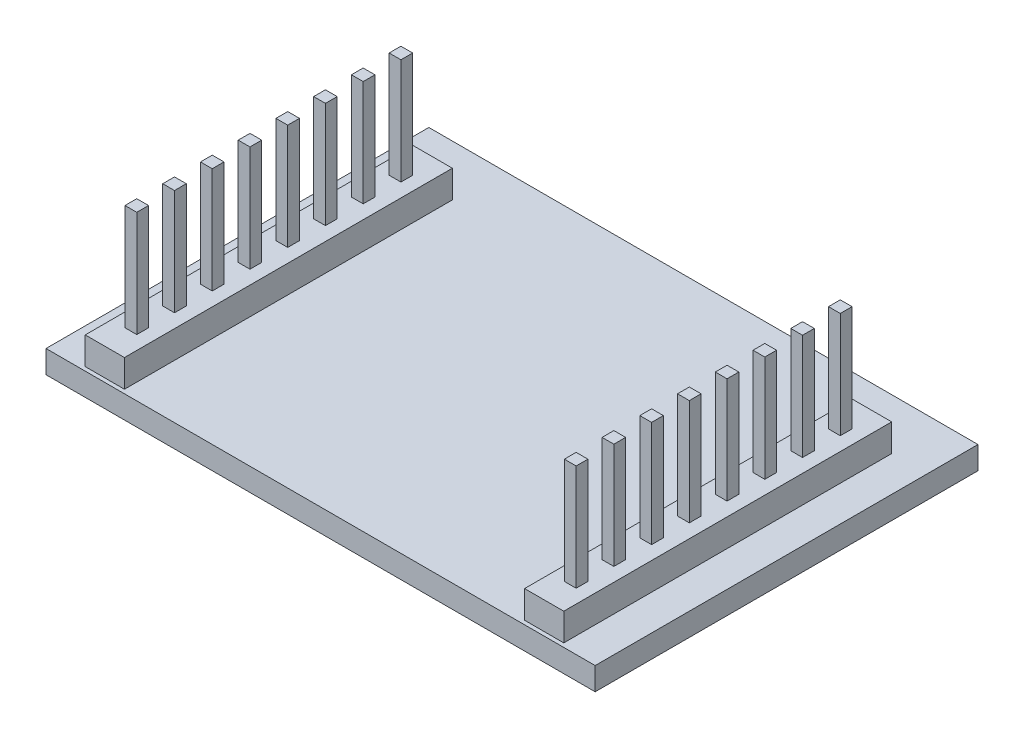
from build123d import *

# Parameters (mm, degrees)
SKETCH1_W           = 35
SKETCH1_H           = 24.4
BOSS_EXTRUDE1_DEPTH = 1.45
SKETCH2_W           = 2.5
SKETCH2_H           = 20.9
SKETCH2_W_2         = 2.498206115
BOSS_EXTRUDE2_DEPTH = 1.75
SKETCH3_W           = 0.75
SKETCH3_H           = 0.75
BOSS_EXTRUDE3_DEPTH = 6.75
SKETCH5_W           = 0.75
SKETCH5_H           = 0.75
BOSS_EXTRUDE4_DEPTH = 6.75
BOSS_EXTRUDE5_DEPTH = 1


with BuildPart() as part:
    # Sketch1 → Boss-Extrude1 (new body)
    with BuildSketch(Plane(origin=(0, 0, 0), x_dir=(1, 0, 0), z_dir=(0, 1, 0))):
        Rectangle(SKETCH1_W, SKETCH1_H)
    extrude(amount=BOSS_EXTRUDE1_DEPTH)

    # Sketch2 → Boss-Extrude2 (add)
    with BuildSketch(Plane(origin=(0, 1.45, 0), x_dir=(1, 0, 0), z_dir=(0, 1, 0))):
        with Locations((-14, -1.5)):
            Rectangle(SKETCH2_W, SKETCH2_H)
        with Locations((14.000896943, -1.5)):
            Rectangle(SKETCH2_W_2, SKETCH2_H)
    extrude(amount=BOSS_EXTRUDE2_DEPTH)

    # Sketch3 → Boss-Extrude3 (add)
    with BuildSketch(Plane(origin=(0, 3.2, 0), x_dir=(1, 0, 0), z_dir=(0, 1, 0))):
        with Locations((-14, 6.92)):
            Rectangle(SKETCH3_W, SKETCH3_H)
        with Locations((-14, 4.515)):
            Rectangle(SKETCH3_W, SKETCH3_H)
        with Locations((-14, 2.11)):
            Rectangle(SKETCH3_W, SKETCH3_H)
        with Locations((-14, -0.295)):
            Rectangle(SKETCH3_W, SKETCH3_H)
        with Locations((-14, -2.7)):
            Rectangle(SKETCH3_W, SKETCH3_H)
        with Locations((-14, -5.105)):
            Rectangle(SKETCH3_W, SKETCH3_H)
        with Locations((-14, -7.51)):
            Rectangle(SKETCH3_W, SKETCH3_H)
        with Locations((-14, -9.915)):
            Rectangle(SKETCH3_W, SKETCH3_H)
    extrude(amount=BOSS_EXTRUDE3_DEPTH)

    # Sketch5 → Boss-Extrude4 (add)
    with BuildSketch(Plane(origin=(0, 3.2, 0), x_dir=(1, 0, 0), z_dir=(0, 1, 0))):
        with Locations((14.001793885, 6.92)):
            Rectangle(SKETCH5_W, SKETCH5_H)
        with Locations((14.001793885, 4.515)):
            Rectangle(SKETCH5_W, SKETCH5_H)
        with Locations((14.001793885, 2.11)):
            Rectangle(SKETCH5_W, SKETCH5_H)
        with Locations((14.001793885, -0.295)):
            Rectangle(SKETCH5_W, SKETCH5_H)
        with Locations((14.001793885, -2.7)):
            Rectangle(SKETCH5_W, SKETCH5_H)
        with Locations((14.001793885, -5.105)):
            Rectangle(SKETCH5_W, SKETCH5_H)
        with Locations((14.001793885, -7.51)):
            Rectangle(SKETCH5_W, SKETCH5_H)
        with Locations((14.001793885, -9.915)):
            Rectangle(SKETCH5_W, SKETCH5_H)
    extrude(amount=BOSS_EXTRUDE4_DEPTH)

    # Sketch6 → Boss-Extrude5 (add)
    with BuildSketch(Plane(origin=(0, 0, 0), x_dir=(-1, 0, 0), z_dir=(0, -1, 0))):
        with BuildLine():
            Line((-10.862530521, 1.602014843), (-11.137370265, 1.391678305))
            add(Edge.make_bspline(
                [(-11.137370265, 1.391678305), (-11.156976153, 1.415044275), (-11.1959236, 1.46146119), (-11.258582803, 1.526640735), (-11.323884446, 1.587705996), (-11.391803567, 1.644947876), (-11.463562686, 1.696364642), (-11.537423485, 1.744635745), (-11.61462153, 1.787903483), (-11.721373265, 1.840366469), (-11.861021113, 1.895112624), (-12.036815952, 1.941015855), (-12.220327051, 1.970237031), (-12.34552465, 1.973401872), (-12.409205201, 1.975011638)],
                knots=[0, 0, 0, 0, 9.1485e-05, 0.000181737, 0.000271024, 0.000359627, 0.000447979, 0.000535687, 0.000624217, 0.000713268, 0.000892422, 0.00107303, 0.001257466, 0.001448389, 0.001448389, 0.001448389, 0.001448389], degree=3))
            add(Edge.make_bspline(
                [(-12.409205201, 1.975011638), (-12.4442885, 1.974607676), (-12.514129493, 1.9738035), (-12.617777966, 1.963194375), (-12.719491017, 1.948283165), (-12.819202484, 1.926157841), (-12.916785442, 1.898185222), (-13.012877844, 1.864759808), (-13.106088444, 1.823404969), (-13.197706682, 1.777696709), (-13.285485893, 1.726069264), (-13.368540941, 1.669755912), (-13.446568909, 1.609386816), (-13.519631521, 1.544735709), (-13.587803469, 1.476093749), (-13.65059078, 1.402729407), (-13.70777619, 1.324877234), (-13.760493216, 1.243563826), (-13.807705949, 1.159026034), (-13.847235828, 1.070950964), (-13.882240951, 0.980846861), (-13.909940193, 0.8876957), (-13.93186471, 0.792152934), (-13.946992373, 0.693962146), (-13.957480844, 0.593328467), (-13.958281021, 0.525119154), (-13.958684368, 0.490736799)],
                knots=[0, 0, 0, 0, 0.000105206, 0.000209435, 0.000312261, 0.00041348, 0.000515565, 0.000616682, 0.000718413, 0.000821258, 0.000923708, 0.001023662, 0.001122111, 0.001219464, 0.00131614, 0.001412112, 0.001508869, 0.001605718, 0.001702691, 0.001799013, 0.001895107, 0.001992482, 0.002090281, 0.00218895, 0.002290387, 0.00239349, 0.00239349, 0.00239349, 0.00239349], degree=3))
            add(Edge.make_bspline(
                [(-13.958684368, 0.490736799), (-13.957422549, 0.439005479), (-13.954945134, 0.337437894), (-13.9328968, 0.188667283), (-13.899391709, 0.046146609), (-13.849176132, -0.089233233), (-13.787257081, -0.219141591), (-13.70901647, -0.341380444), (-13.618399933, -0.457797009), (-13.514125513, -0.565639957), (-13.399719697, -0.664153682), (-13.276971785, -0.750904263), (-13.146187498, -0.823219146), (-13.008810867, -0.883395092), (-12.863784754, -0.92965182), (-12.711369951, -0.962215944), (-12.551897956, -0.983458124), (-12.442928556, -0.985491812), (-12.387470425, -0.986526823)],
                knots=[0, 0, 0, 0, 0.000155106, 0.000304531, 0.000450265, 0.000593548, 0.000736853, 0.000881182, 0.001028026, 0.001178769, 0.001330408, 0.001480379, 0.001628835, 0.001777978, 0.001929641, 0.002084627, 0.002245075, 0.00241136, 0.00241136, 0.00241136, 0.00241136], degree=3))
            add(Edge.make_bspline(
                [(-12.387470425, -0.986526823), (-12.326367736, -0.984838044), (-12.206103027, -0.981514121), (-12.029735001, -0.953354872), (-11.860899235, -0.907696954), (-11.699586649, -0.843799032), (-11.546252003, -0.760733744), (-11.400655342, -0.660035866), (-11.262673772, -0.540747534), (-11.17970249, -0.449664405), (-11.137370265, -0.40319349)],
                knots=[0, 0, 0, 0, 0.00018322, 0.00036062, 0.000534275, 0.000707044, 0.000879893, 0.001056289, 0.001237208, 0.001425665, 0.001425665, 0.001425665, 0.001425665], degree=3))
            Line((-11.137370265, -0.40319349), (-10.862530521, -0.611426663))
            add(Edge.make_bspline(
                [(-10.862530521, -0.611426663), (-10.884648631, -0.639965115), (-10.928778907, -0.696905321), (-11.000236924, -0.777177031), (-11.075514221, -0.852681066), (-11.155169931, -0.922808688), (-11.238287723, -0.988963153), (-11.326360035, -1.049264985), (-11.418229067, -1.104555869), (-11.513583546, -1.155182793), (-11.612322159, -1.20010004), (-11.714326594, -1.238553808), (-11.81915717, -1.271678698), (-11.926818678, -1.298930634), (-12.037534435, -1.320201718), (-12.150904909, -1.334421393), (-12.267174784, -1.344163308), (-12.345616205, -1.345051223), (-12.38536706, -1.345501182)],
                knots=[0, 0, 0, 0, 0.000108293, 0.000216068, 0.000322162, 0.000427957, 0.000534281, 0.00064066, 0.000747915, 0.000855806, 0.000964371, 0.001073102, 0.001182643, 0.001294024, 0.001406092, 0.001520624, 0.001636667, 0.001755891, 0.001755891, 0.001755891, 0.001755891], degree=3))
            add(Edge.make_bspline(
                [(-12.38536706, -1.345501182), (-12.423010727, -1.34523919), (-12.497446417, -1.344721132), (-12.607345169, -1.336328964), (-12.714334749, -1.324879228), (-12.818109375, -1.307639096), (-12.91923535, -1.287294756), (-13.016795935, -1.2600235), (-13.111751145, -1.229474333), (-13.203719486, -1.193569346), (-13.292779186, -1.153053164), (-13.378642997, -1.107261605), (-13.461271429, -1.05657974), (-13.54147685, -1.00212473), (-13.618074434, -0.942147428), (-13.691727959, -0.877480794), (-13.762850436, -0.808342783), (-13.806853121, -0.758487929), (-13.828976835, -0.733421855)],
                knots=[0, 0, 0, 0, 0.0001129, 0.000223246, 0.000330481, 0.000435603, 0.000538732, 0.000639764, 0.000739316, 0.000837878, 0.000935767, 0.001032686, 0.001129604, 0.00122645, 0.001323362, 0.001421241, 0.001520399, 0.001620667, 0.001620667, 0.001620667, 0.001620667], degree=3))
            add(Edge.make_bspline(
                [(-13.828976835, -0.733421855), (-13.864412479, -0.689880666), (-13.934855956, -0.603323956), (-14.024981639, -0.463037975), (-14.102129195, -0.316569766), (-14.164505115, -0.163149837), (-14.213267849, -0.00312245), (-14.247049044, 0.163593065), (-14.269000648, 0.336841007), (-14.271510937, 0.454677795), (-14.272786932, 0.51457494)],
                knots=[0, 0, 0, 0, 0.000168306, 0.00033458, 0.000499224, 0.000664315, 0.00083066, 0.00100034, 0.001174094, 0.001353718, 0.001353718, 0.001353718, 0.001353718], degree=3))
            add(Edge.make_bspline(
                [(-14.272786932, 0.51457494), (-14.271231738, 0.577530393), (-14.268171992, 0.701391318), (-14.242176196, 0.883165271), (-14.2003574, 1.05731667), (-14.140960512, 1.223520414), (-14.06565516, 1.382650695), (-13.972628546, 1.533491899), (-13.862961404, 1.677008699), (-13.737513837, 1.81102345), (-13.599946501, 1.933562803), (-13.452627687, 2.041369007), (-13.29584574, 2.131086523), (-13.131327889, 2.206082685), (-12.957842207, 2.263727148), (-12.775758838, 2.304080335), (-12.585419923, 2.329197451), (-12.455557498, 2.332372659), (-12.389573791, 2.333985997)],
                knots=[0, 0, 0, 0, 0.000188789, 0.000371431, 0.000549644, 0.000725278, 0.00089996, 0.001076844, 0.001255917, 0.001440951, 0.001626689, 0.001807878, 0.001987546, 0.002167657, 0.002349462, 0.002534866, 0.002726448, 0.002924344, 0.002924344, 0.002924344, 0.002924344], degree=3))
            add(Edge.make_bspline(
                [(-12.389573791, 2.333985997), (-12.349359319, 2.333503859), (-12.269758821, 2.332549515), (-12.152006169, 2.323243373), (-12.037363842, 2.307729767), (-11.92575286, 2.286613697), (-11.816630244, 2.260406375), (-11.710830003, 2.226266077), (-11.607731316, 2.187229546), (-11.507984408, 2.14227108), (-11.412067858, 2.091804338), (-11.320011539, 2.036388715), (-11.232546681, 1.976092909), (-11.149057832, 1.911429734), (-11.070941621, 1.841031175), (-10.995980142, 1.766833579), (-10.926719064, 1.686699755), (-10.883965869, 1.630294821), (-10.862530521, 1.602014843)],
                knots=[0, 0, 0, 0, 0.000120626, 0.000238766, 0.000354085, 0.000467531, 0.000579423, 0.000690512, 0.000800803, 0.000910007, 0.001018518, 0.001125773, 0.001232152, 0.001337058, 0.001442329, 0.001547432, 0.001653292, 0.001759736, 0.001759736, 0.001759736, 0.001759736], degree=3))
        make_face()
        with BuildLine():
            Line((-10.279197188, 1.301934715), (-9.965094624, 1.301934715))
            Line((-9.965094624, 1.301934715), (-9.965094624, 0.115636638))
            add(Edge.make_bspline(
                [(-9.965094624, 0.115636638), (-9.964952719, 0.080813889), (-9.964681262, 0.014199601), (-9.962840321, -0.081655586), (-9.958510227, -0.169072298), (-9.953096403, -0.248101035), (-9.946134266, -0.318728427), (-9.937850906, -0.380707784), (-9.928592484, -0.434741968), (-9.91952977, -0.467285324), (-9.915314977, -0.482420253)],
                knots=[0, 0, 0, 0, 0.00010447, 0.000199845, 0.000287586, 0.000367011, 0.000437473, 0.000500438, 0.00055462, 0.000601725, 0.000601725, 0.000601725, 0.000601725], degree=3))
            add(Edge.make_bspline(
                [(-9.915314977, -0.482420253), (-9.908553522, -0.501443124), (-9.89517118, -0.539093385), (-9.870897697, -0.59348239), (-9.84086936, -0.643857672), (-9.808009532, -0.692161745), (-9.770110125, -0.736963732), (-9.727650654, -0.778187976), (-9.682052417, -0.817392067), (-9.614297393, -0.863776859), (-9.521638127, -0.913492189), (-9.399985372, -0.956388007), (-9.268081146, -0.982023827), (-9.176916427, -0.984998082), (-9.130058566, -0.986526823)],
                knots=[0, 0, 0, 0, 6.0561e-05, 0.000119863, 0.000178304, 0.000236261, 0.000294971, 0.000353969, 0.000413668, 0.000475127, 0.000599968, 0.00072792, 0.000860749, 0.001001226, 0.001001226, 0.001001226, 0.001001226], degree=3))
            add(Edge.make_bspline(
                [(-9.130058566, -0.986526823), (-9.083205059, -0.984965575), (-8.99255219, -0.981944848), (-8.862097221, -0.957161309), (-8.742845807, -0.91575562), (-8.635994855, -0.857948208), (-8.542029015, -0.787206145), (-8.463724596, -0.704197337), (-8.399117342, -0.61154795), (-8.370907921, -0.542423671), (-8.356721227, -0.507660637)],
                knots=[0, 0, 0, 0, 0.000140477, 0.000271796, 0.000396637, 0.000517726, 0.000634816, 0.00074789, 0.000858929, 0.000971266, 0.000971266, 0.000971266, 0.000971266], degree=3))
            add(Edge.make_bspline(
                [(-8.356721227, -0.507660637), (-8.352526996, -0.493694339), (-8.343254578, -0.462818263), (-8.333292227, -0.410438515), (-8.324317765, -0.34797391), (-8.316654589, -0.275015702), (-8.311189426, -0.191754549), (-8.3082434, -0.098216473), (-8.304915124, 0.005304887), (-8.304864608, 0.077772646), (-8.304838214, 0.115636638)],
                knots=[0, 0, 0, 0, 4.3723e-05, 9.6661e-05, 0.000159723, 0.000233047, 0.000316669, 0.000409984, 0.000513788, 0.000627372, 0.000627372, 0.000627372, 0.000627372], degree=3))
            Line((-8.304838214, 0.115636638), (-8.304838214, 1.301934715))
            Line((-8.304838214, 1.301934715), (-7.99073565, 1.301934715))
            Line((-7.99073565, 1.301934715), (-7.99073565, 0.056742407))
            add(Edge.make_bspline(
                [(-7.99073565, 0.056742407), (-7.991177344, 0.014435236), (-7.992034293, -0.067646464), (-7.997541636, -0.186930575), (-8.006991249, -0.29809282), (-8.021333934, -0.40119204), (-8.038199609, -0.496149522), (-8.059955881, -0.583086968), (-8.085934119, -0.661736522), (-8.115239634, -0.733478299), (-8.149861502, -0.798525193), (-8.186688522, -0.860261009), (-8.229213294, -0.917153945), (-8.273983528, -0.972036082), (-8.323785184, -1.022177609), (-8.377685043, -1.068729085), (-8.434924463, -1.112402117), (-8.496773661, -1.151493396), (-8.562329724, -1.186710042), (-8.631673581, -1.21792612), (-8.705654579, -1.242628697), (-8.783318216, -1.263939363), (-8.865044995, -1.280653832), (-8.950756129, -1.292440398), (-9.040422745, -1.299665729), (-9.101532204, -1.300302774), (-9.132863053, -1.300629387)],
                knots=[0, 0, 0, 0, 0.00012692, 0.000246243, 0.000358153, 0.000461473, 0.000558423, 0.000647357, 0.000730057, 0.000806749, 0.000879504, 0.000950929, 0.001022168, 0.001092368, 0.001163264, 0.001233837, 0.001305913, 0.001379045, 0.001453076, 0.001529034, 0.001606858, 0.001686798, 0.001770538, 0.001856901, 0.001946219, 0.002040193, 0.002040193, 0.002040193, 0.002040193], degree=3))
            add(Edge.make_bspline(
                [(-9.132863053, -1.300629387), (-9.163959568, -1.30028968), (-9.225067113, -1.299622124), (-9.314738357, -1.292480316), (-9.400686963, -1.280672146), (-9.482607362, -1.263816928), (-9.560581759, -1.242777858), (-9.634925999, -1.217774323), (-9.704769562, -1.186693841), (-9.770951566, -1.151716284), (-9.832953954, -1.112151008), (-9.891062532, -1.068782969), (-9.945199385, -1.021676906), (-9.995376453, -0.971029548), (-10.040889429, -0.916212612), (-10.082305471, -0.857667052), (-10.120262176, -0.795972963), (-10.154614967, -0.729909801), (-10.184126722, -0.657337791), (-10.210181968, -0.577040694), (-10.231492606, -0.488138177), (-10.248835075, -0.390706249), (-10.262786515, -0.285211207), (-10.272472658, -0.171042792), (-10.277888488, -0.0484791), (-10.27875155, 0.03617079), (-10.279197188, 0.079879427)],
                knots=[0, 0, 0, 0, 9.3273e-05, 0.00018329, 0.000269653, 0.000353393, 0.000434009, 0.000511834, 0.000588433, 0.000663082, 0.000736214, 0.00080885, 0.000880413, 0.000951309, 0.001022496, 0.001093894, 0.001166283, 0.00123966, 0.001317, 0.001401032, 0.001492689, 0.001591018, 0.001697812, 0.001811817, 0.001934642, 0.002065769, 0.002065769, 0.002065769, 0.002065769], degree=3))
            Line((-10.279197188, 0.079879427), (-10.279197188, 1.301934715))
        make_face()
        with BuildLine():
            Line((-6.06124847, 0.982924299), (-6.274389496, 0.763473177))
            add(Edge.make_bspline(
                [(-6.274389496, 0.763473177), (-6.292779999, 0.784786323), (-6.328234725, 0.82587556), (-6.384466206, 0.880812627), (-6.44048981, 0.926949566), (-6.495538623, 0.965901824), (-6.550996892, 0.995350971), (-6.60621381, 1.016845833), (-6.661246549, 1.030147639), (-6.698032584, 1.031862077), (-6.716096227, 1.032703946)],
                knots=[0, 0, 0, 0, 8.4426e-05, 0.000162764, 0.000235478, 0.000301992, 0.000364722, 0.000423315, 0.00047944, 0.00053359, 0.00053359, 0.00053359, 0.00053359], degree=3))
            add(Edge.make_bspline(
                [(-6.716096227, 1.032703946), (-6.738235616, 1.031629073), (-6.781802802, 1.029513875), (-6.844228621, 1.008400445), (-6.902179246, 0.975991706), (-6.952336226, 0.930023123), (-6.994823906, 0.877258854), (-7.025837587, 0.818262529), (-7.04480357, 0.754814485), (-7.047208302, 0.710784628), (-7.048427957, 0.688453145)],
                knots=[0, 0, 0, 0, 6.6207e-05, 0.000130286, 0.000195595, 0.000264126, 0.000333001, 0.000397918, 0.000462926, 0.000529831, 0.000529831, 0.000529831, 0.000529831], degree=3))
            add(Edge.make_bspline(
                [(-7.048427957, 0.688453145), (-7.047317145, 0.668241101), (-7.045098652, 0.62787399), (-7.027851973, 0.568325956), (-7.0003859, 0.510268918), (-6.974715706, 0.474706011), (-6.961488855, 0.456381831)],
                knots=[0, 0, 0, 0, 6.0557e-05, 0.000120943, 0.000184606, 0.000252278, 0.000252278, 0.000252278, 0.000252278], degree=3))
            add(Edge.make_bspline(
                [(-6.961488855, 0.456381831), (-6.953525361, 0.446597246), (-6.936576068, 0.425771992), (-6.904767553, 0.396868138), (-6.86874505, 0.364925887), (-6.825425113, 0.33298905), (-6.776674085, 0.299357325), (-6.7214348, 0.265355192), (-6.661460296, 0.228390767), (-6.618522989, 0.204946332), (-6.5962044, 0.192760036)],
                knots=[0, 0, 0, 0, 3.7796e-05, 8.0443e-05, 0.000128658, 0.000182224, 0.000241732, 0.000306315, 0.000376777, 0.000453048, 0.000453048, 0.000453048, 0.000453048], degree=3))
            add(Edge.make_bspline(
                [(-6.5962044, 0.192760036), (-6.568990822, 0.177515133), (-6.516423152, 0.148067), (-6.441730385, 0.102357297), (-6.373943344, 0.056925873), (-6.312487677, 0.012258599), (-6.258545868, -0.032894269), (-6.210481315, -0.076802026), (-6.169492871, -0.120791334), (-6.146538944, -0.151524448), (-6.13556738, -0.166214323)],
                knots=[0, 0, 0, 0, 9.3573e-05, 0.000180752, 0.000262618, 0.000338343, 0.000408542, 0.000473535, 0.000533574, 0.000588549, 0.000588549, 0.000588549, 0.000588549], degree=3))
            add(Edge.make_bspline(
                [(-6.13556738, -0.166214323), (-6.117356853, -0.195880411), (-6.081114524, -0.254921432), (-6.043056257, -0.35213986), (-6.020995982, -0.455250362), (-6.017933762, -0.525782582), (-6.016376675, -0.561647016)],
                knots=[0, 0, 0, 0, 0.000104269, 0.000207515, 0.000311475, 0.000419024, 0.000419024, 0.000419024, 0.000419024], degree=3))
            add(Edge.make_bspline(
                [(-6.016376675, -0.561647016), (-6.017096209, -0.586916162), (-6.018514129, -0.636711775), (-6.028372196, -0.710046605), (-6.045327172, -0.780181162), (-6.068420926, -0.847876447), (-6.099605299, -0.911835387), (-6.136153096, -0.973671636), (-6.180028008, -1.032047566), (-6.230119384, -1.086886526), (-6.284964878, -1.136972274), (-6.343471016, -1.180996228), (-6.405709847, -1.217570565), (-6.471236648, -1.24783591), (-6.540200302, -1.271904168), (-6.612611591, -1.288566699), (-6.688240346, -1.29853946), (-6.739670154, -1.299923937), (-6.765875874, -1.300629387)],
                knots=[0, 0, 0, 0, 7.5802e-05, 0.000149377, 0.00022148, 0.00029199, 0.000363491, 0.000434554, 0.00050719, 0.000582132, 0.000657073, 0.000729709, 0.000801375, 0.000873212, 0.000945939, 0.001020089, 0.001095749, 0.001174353, 0.001174353, 0.001174353, 0.001174353], degree=3))
            add(Edge.make_bspline(
                [(-6.765875874, -1.300629387), (-6.801243049, -1.299636687), (-6.871485976, -1.29766508), (-6.975375695, -1.279159019), (-7.076896454, -1.250363625), (-7.175279994, -1.210647691), (-7.268326108, -1.160496978), (-7.353457033, -1.100434584), (-7.430968495, -1.032444587), (-7.475086769, -0.980331676), (-7.497145906, -0.954275221)],
                knots=[0, 0, 0, 0, 0.000106018, 0.000210563, 0.000315537, 0.000422167, 0.000528204, 0.00063188, 0.000734181, 0.000836482, 0.000836482, 0.000836482, 0.000836482], degree=3))
            Line((-7.497145906, -0.954275221), (-7.288912733, -0.717296054))
            add(Edge.make_bspline(
                [(-7.288912733, -0.717296054), (-7.26914032, -0.738650819), (-7.230808508, -0.780050259), (-7.169507291, -0.835174599), (-7.10712789, -0.88137587), (-7.044293203, -0.920019285), (-6.980073109, -0.949794688), (-6.914827495, -0.970713282), (-6.848689071, -0.984157474), (-6.804266935, -0.985735757), (-6.782001675, -0.986526823)],
                knots=[0, 0, 0, 0, 8.7278e-05, 0.000169201, 0.000246886, 0.000319874, 0.000390144, 0.000458657, 0.000525071, 0.00059181, 0.00059181, 0.00059181, 0.00059181], degree=3))
            add(Edge.make_bspline(
                [(-6.782001675, -0.986526823), (-6.751683749, -0.985155998), (-6.692447608, -0.982477637), (-6.607603849, -0.958160545), (-6.529265223, -0.920030593), (-6.461241877, -0.865945895), (-6.403339716, -0.802990322), (-6.361411542, -0.732076203), (-6.335135366, -0.655284746), (-6.332049368, -0.602052443), (-6.330479239, -0.57496833)],
                knots=[0, 0, 0, 0, 9.0773e-05, 0.000177355, 0.000262642, 0.000350576, 0.00043646, 0.000517865, 0.000596131, 0.000677197, 0.000677197, 0.000677197, 0.000677197], degree=3))
            add(Edge.make_bspline(
                [(-6.330479239, -0.57496833), (-6.331565534, -0.552658711), (-6.333710276, -0.508611355), (-6.350553548, -0.444861014), (-6.377166401, -0.384391734), (-6.403371049, -0.349002086), (-6.41671722, -0.330977945)],
                knots=[0, 0, 0, 0, 6.6842e-05, 0.000131971, 0.000196611, 0.000263703, 0.000263703, 0.000263703, 0.000263703], degree=3))
            add(Edge.make_bspline(
                [(-6.41671722, -0.330977945), (-6.424739615, -0.321942583), (-6.442215287, -0.302260301), (-6.474270528, -0.273835222), (-6.51265239, -0.243197123), (-6.557792553, -0.210865534), (-6.609782015, -0.177266929), (-6.668831491, -0.142577576), (-6.734132043, -0.105149851), (-6.780302675, -0.080330195), (-6.804437573, -0.06735615)],
                knots=[0, 0, 0, 0, 3.6222e-05, 7.8904e-05, 0.000128287, 0.000183547, 0.000245389, 0.000313927, 0.000388976, 0.000471175, 0.000471175, 0.000471175, 0.000471175], degree=3))
            add(Edge.make_bspline(
                [(-6.804437573, -0.06735615), (-6.830484213, -0.052817019), (-6.88099696, -0.024621002), (-6.952544251, 0.019295078), (-7.017091605, 0.063962353), (-7.07619218, 0.106875192), (-7.128353186, 0.150296136), (-7.173369134, 0.194273387), (-7.21301235, 0.237033373), (-7.234959761, 0.26733067), (-7.245443182, 0.281802504)],
                knots=[0, 0, 0, 0, 8.9486e-05, 0.000173541, 0.000251719, 0.000324918, 0.000392605, 0.000455079, 0.000513655, 0.000567221, 0.000567221, 0.000567221, 0.000567221], degree=3))
            add(Edge.make_bspline(
                [(-7.245443182, 0.281802504), (-7.263573781, 0.310948119), (-7.299841317, 0.369249534), (-7.335056508, 0.466560011), (-7.359262537, 0.569005068), (-7.361424927, 0.639691922), (-7.362530521, 0.675832952)],
                knots=[0, 0, 0, 0, 0.000102704, 0.000205444, 0.000308869, 0.000417069, 0.000417069, 0.000417069, 0.000417069], degree=3))
            add(Edge.make_bspline(
                [(-7.362530521, 0.675832952), (-7.361996326, 0.69945835), (-7.36095083, 0.745696601), (-7.352606779, 0.813635422), (-7.337415067, 0.878183575), (-7.318360145, 0.940310438), (-7.29187714, 0.998812532), (-7.260231235, 1.054470004), (-7.22304381, 1.107205922), (-7.180200519, 1.156209054), (-7.133093874, 1.20071838), (-7.082199104, 1.239517008), (-7.028660848, 1.272623363), (-6.972252428, 1.300388523), (-6.912431955, 1.321389906), (-6.849617569, 1.335847291), (-6.783936414, 1.345502494), (-6.739035288, 1.346365578), (-6.716096227, 1.34680651)],
                knots=[0, 0, 0, 0, 7.0869e-05, 0.0001387, 0.000204863, 0.000269609, 0.000333323, 0.000397067, 0.000461456, 0.000526554, 0.000592026, 0.00065555, 0.000718201, 0.000780601, 0.000843799, 0.000907913, 0.000973751, 0.001042518, 0.001042518, 0.001042518, 0.001042518], degree=3))
            add(Edge.make_bspline(
                [(-6.716096227, 1.34680651), (-6.688904163, 1.345702169), (-6.634009941, 1.343472772), (-6.551655315, 1.325767081), (-6.469421973, 1.296633977), (-6.387098623, 1.256397744), (-6.305288334, 1.204330868), (-6.223271477, 1.141401568), (-6.140063447, 1.068023854), (-6.088107134, 1.011924628), (-6.06124847, 0.982924299)],
                knots=[0, 0, 0, 0, 8.1523e-05, 0.000164576, 0.000251498, 0.000342746, 0.000438841, 0.000541908, 0.000652652, 0.000771167, 0.000771167, 0.000771167, 0.000771167], degree=3))
        make_face()
        Polygon((-5.074068983, 2.333985997), (-4.759966419, 2.333985997), (-4.759966419, 1.301934715), (-4.31124847, 1.301934715), (-4.31124847, 0.987832151), (-4.759966419, 0.987832151), (-4.759966419, -1.255757593), (-5.074068983, -1.255757593), (-5.074068983, 0.987832151), (-5.522786932, 0.987832151), (-5.522786932, 1.301934715), (-5.074068983, 1.301934715), align=None)
        with BuildLine():
            add(Edge.make_bspline(
                [(-2.537410329, 1.34680651), (-2.489419056, 1.345784619), (-2.395319899, 1.34378094), (-2.257512013, 1.322365974), (-2.125966877, 1.28961861), (-2.000180685, 1.244347048), (-1.881764389, 1.183665097), (-1.768993145, 1.111255806), (-1.662176136, 1.025473213), (-1.598153107, 0.959115144), (-1.565655521, 0.925432311)],
                knots=[0, 0, 0, 0, 0.000143868, 0.000282091, 0.000417278, 0.000550139, 0.000682145, 0.000815559, 0.000951665, 0.001091969, 0.001091969, 0.001091969, 0.001091969], degree=3))
            add(Edge.make_bspline(
                [(-1.565655521, 0.925432311), (-1.537673567, 0.893218326), (-1.482251187, 0.829413783), (-1.411185468, 0.72595817), (-1.349963908, 0.61881807), (-1.300900947, 0.506570743), (-1.262215923, 0.390196072), (-1.234750227, 0.269294061), (-1.218413292, 0.144131714), (-1.216210325, 0.059127876), (-1.215094624, 0.016077343)],
                knots=[0, 0, 0, 0, 0.000127922, 0.000253368, 0.000375813, 0.000497617, 0.000620225, 0.000743195, 0.000869033, 0.000998161, 0.000998161, 0.000998161, 0.000998161], degree=3))
            add(Edge.make_bspline(
                [(-1.215094624, 0.016077343), (-1.216075961, -0.027222714), (-1.21801513, -0.112785648), (-1.236358746, -0.238805013), (-1.264889832, -0.360999836), (-1.30572167, -0.47885853), (-1.358079779, -0.592741357), (-1.421970467, -0.702150907), (-1.497842084, -0.80730304), (-1.583846081, -0.907304878), (-1.678897957, -0.999471093), (-1.782014105, -1.079799362), (-1.891168139, -1.148620887), (-2.007811492, -1.204057302), (-2.130878979, -1.247767003), (-2.260636047, -1.278467019), (-2.396881117, -1.297028703), (-2.489908339, -1.299412276), (-2.537410329, -1.300629387)],
                knots=[0, 0, 0, 0, 0.000129829, 0.000256548, 0.000381202, 0.000505812, 0.000630045, 0.000756669, 0.000885282, 0.001018518, 0.001151902, 0.001281775, 0.001409974, 0.001538236, 0.001668405, 0.001801048, 0.001937587, 0.002080055, 0.002080055, 0.002080055, 0.002080055], degree=3))
            add(Edge.make_bspline(
                [(-2.537410329, -1.300629387), (-2.585145049, -1.299408191), (-2.678635908, -1.297016417), (-2.81536189, -1.278539134), (-2.945351509, -1.247781151), (-3.068580108, -1.203913659), (-3.185724955, -1.148619115), (-3.295511452, -1.080007425), (-3.398711367, -0.99944727), (-3.493783352, -0.907311333), (-3.579781957, -0.807301377), (-3.655654965, -0.702151338), (-3.719545291, -0.592741245), (-3.771903495, -0.47885856), (-3.812735308, -0.360999828), (-3.841266401, -0.238805016), (-3.859610015, -0.112785647), (-3.861549184, -0.027222714), (-3.862530521, 0.016077343)],
                knots=[0, 0, 0, 0, 0.000143168, 0.000280402, 0.000413045, 0.000543214, 0.000672108, 0.000800903, 0.000930775, 0.00106416, 0.001197395, 0.001326009, 0.001452632, 0.001576866, 0.001701476, 0.00182613, 0.001952849, 0.002082678, 0.002082678, 0.002082678, 0.002082678], degree=3))
            add(Edge.make_bspline(
                [(-3.862530521, 0.016077343), (-3.861407211, 0.058893889), (-3.85918325, 0.143663292), (-3.842862741, 0.268590352), (-3.815504184, 0.389287741), (-3.776772788, 0.505213217), (-3.727257597, 0.616968653), (-3.666896309, 0.724373484), (-3.595105676, 0.827361285), (-3.539903725, 0.891083365), (-3.511969624, 0.923328946)],
                knots=[0, 0, 0, 0, 0.000128428, 0.000254265, 0.000377235, 0.000499178, 0.000620341, 0.000743397, 0.000868267, 0.000996189, 0.000996189, 0.000996189, 0.000996189], degree=3))
            add(Edge.make_bspline(
                [(-3.511969624, 0.923328946), (-3.479521033, 0.957303885), (-3.415705169, 1.024121581), (-3.308356441, 1.109654105), (-3.19586262, 1.183570179), (-3.076137694, 1.243046395), (-2.950454836, 1.289884913), (-2.818235594, 1.322450428), (-2.679960078, 1.343703783), (-2.585400457, 1.34576196), (-2.537410329, 1.34680651)],
                knots=[0, 0, 0, 0, 0.000140798, 0.000276904, 0.000410699, 0.000543958, 0.000677061, 0.000812248, 0.000951858, 0.001095726, 0.001095726, 0.001095726, 0.001095726], degree=3))
        make_face()
        with BuildLine():
            add(Edge.make_bspline(
                [(-2.538812573, 1.032703946), (-2.572750184, 1.031739354), (-2.639749313, 1.029835072), (-2.738368897, 1.015351167), (-2.833309051, 0.992403663), (-2.924749895, 0.959799607), (-3.012383068, 0.917700708), (-3.09629247, 0.865992348), (-3.17672491, 0.805359391), (-3.252106974, 0.735896719), (-3.321289286, 0.660017725), (-3.381767262, 0.579169366), (-3.433192369, 0.49466302), (-3.476032528, 0.406410809), (-3.507939716, 0.313518395), (-3.531112738, 0.217037763), (-3.545582979, 0.116772347), (-3.547469357, 0.048611329), (-3.548427957, 0.013973978)],
                knots=[0, 0, 0, 0, 0.000101781, 0.000200935, 0.000298373, 0.000394396, 0.000491609, 0.000589491, 0.000689611, 0.000793323, 0.000896562, 0.000997243, 0.001095722, 0.001192936, 0.001290943, 0.001389744, 0.001490285, 0.001594167, 0.001594167, 0.001594167, 0.001594167], degree=3))
            add(Edge.make_bspline(
                [(-3.548427957, 0.013973978), (-3.546821134, -0.030778049), (-3.543631889, -0.119602455), (-3.517696653, -0.250413577), (-3.474310373, -0.375995429), (-3.415723093, -0.495611815), (-3.342316874, -0.606284094), (-3.255829808, -0.704955578), (-3.157190107, -0.790141389), (-3.047573607, -0.860822235), (-2.929219289, -0.916981991), (-2.803962968, -0.956780966), (-2.673322274, -0.982652659), (-2.584041543, -0.985224133), (-2.538812573, -0.986526823)],
                knots=[0, 0, 0, 0, 0.000134178, 0.000266319, 0.000398243, 0.00053182, 0.000664828, 0.000795487, 0.000924236, 0.001054533, 0.001185628, 0.001316003, 0.001448011, 0.001583547, 0.001583547, 0.001583547, 0.001583547], degree=3))
            add(Edge.make_bspline(
                [(-2.538812573, -0.986526823), (-2.493586204, -0.985216543), (-2.404310608, -0.982630086), (-2.273851431, -0.956911266), (-2.148937459, -0.916807606), (-2.030706072, -0.860885396), (-1.921139468, -0.789872981), (-1.821790347, -0.705436604), (-1.736041736, -0.606022753), (-1.662708131, -0.495465224), (-1.603161388, -0.376180872), (-1.559978186, -0.250390399), (-1.5339806, -0.119608358), (-1.530799772, -0.030780027), (-1.529197188, 0.013973978)],
                knots=[0, 0, 0, 0, 0.000135536, 0.000267545, 0.000397252, 0.000528347, 0.000658644, 0.000787925, 0.000918122, 0.00105113, 0.001185017, 0.001316942, 0.001449082, 0.00158326, 0.00158326, 0.00158326, 0.00158326], degree=3))
            add(Edge.make_bspline(
                [(-1.529197188, 0.013973978), (-1.530155458, 0.048611536), (-1.532041187, 0.116772961), (-1.546516152, 0.217035415), (-1.569671691, 0.313527012), (-1.601643308, 0.406379015), (-1.644297322, 0.494891519), (-1.696714115, 0.578921246), (-1.756945141, 0.660297792), (-1.826962262, 0.735651433), (-1.90226564, 0.80538647), (-1.982730678, 0.866015859), (-2.066515656, 0.917473455), (-2.153894239, 0.960159695), (-2.245346807, 0.992107035), (-2.340153936, 1.015483667), (-2.438352746, 1.029773864), (-2.505111789, 1.031721005), (-2.538812573, 1.032703946)],
                knots=[0, 0, 0, 0, 0.000103882, 0.000204424, 0.000303225, 0.000401232, 0.000498445, 0.000597291, 0.000697972, 0.000801684, 0.000905395, 0.001005516, 0.001103397, 0.001199979, 0.001296663, 0.00139342, 0.001492573, 0.001593654, 0.001593654, 0.001593654, 0.001593654], degree=3))
        make_face(mode=Mode.SUBTRACT)
        with BuildLine():
            Line((-0.586889496, 1.301934715), (-0.272786932, 1.301934715))
            Line((-0.272786932, 1.301934715), (-0.272786932, 0.857423497))
            add(Edge.make_bspline(
                [(-0.272786932, 0.857423497), (-0.244502982, 0.896311099), (-0.190308222, 0.970823472), (-0.10144257, 1.069013756), (-0.012666457, 1.152341911), (0.051266925, 1.196084783), (0.081980697, 1.217098978)],
                knots=[0, 0, 0, 0, 0.000144152, 0.000276209, 0.000396804, 0.000508302, 0.000508302, 0.000508302, 0.000508302], degree=3))
            add(Edge.make_bspline(
                [(0.081980697, 1.217098978), (0.123845359, 1.237104343), (0.206843258, 1.276765557), (0.338262483, 1.316999116), (0.472737153, 1.341724217), (0.563545367, 1.34510559), (0.609224286, 1.34680651)],
                knots=[0, 0, 0, 0, 0.000139031, 0.000275633, 0.000410962, 0.000547939, 0.000547939, 0.000547939, 0.000547939], degree=3))
            add(Edge.make_bspline(
                [(0.609224286, 1.34680651), (0.640117283, 1.345761219), (0.701252862, 1.343692645), (0.791836952, 1.33023261), (0.879695564, 1.306966437), (0.964309593, 1.274559113), (1.044030272, 1.235312426), (1.11711947, 1.189262718), (1.182743678, 1.137565643), (1.24086973, 1.07788671), (1.293138755, 1.008550111), (1.341217602, 0.927685862), (1.385642814, 0.833478201), (1.410264123, 0.76511166), (1.42322669, 0.729118209)],
                knots=[0, 0, 0, 0, 9.2678e-05, 0.000183405, 0.000274048, 0.000364807, 0.000454797, 0.00054019, 0.000623517, 0.000704829, 0.000789387, 0.000883415, 0.000986597, 0.001101318, 0.001101318, 0.001101318, 0.001101318], degree=3))
            add(Edge.make_bspline(
                [(1.42322669, 0.729118209), (1.436937942, 0.753842628), (1.463919759, 0.802496813), (1.509225396, 0.871355075), (1.556693192, 0.935761867), (1.606727685, 0.995768291), (1.659152272, 1.051078022), (1.714213672, 1.101873924), (1.771598454, 1.148374137), (1.851390694, 1.202697297), (1.955203301, 1.260398478), (2.086091416, 1.310426922), (2.222241587, 1.34134305), (2.314659286, 1.344973323), (2.361327652, 1.34680651)],
                knots=[0, 0, 0, 0, 8.4789e-05, 0.000166854, 0.000247064, 0.000324714, 0.000401089, 0.000475513, 0.000549314, 0.000622436, 0.0007649, 0.000904487, 0.001041601, 0.001181469, 0.001181469, 0.001181469, 0.001181469], degree=3))
            add(Edge.make_bspline(
                [(2.361327652, 1.34680651), (2.404209115, 1.345189289), (2.488132301, 1.342024231), (2.610309566, 1.317170758), (2.724251372, 1.27449311), (2.829728448, 1.216259474), (2.924888261, 1.143080291), (3.007604571, 1.056011453), (3.077374934, 0.95566883), (3.122953574, 0.861276841), (3.153868838, 0.777941508), (3.172930072, 0.706935217), (3.189769767, 0.628783664), (3.203751012, 0.543393403), (3.213969565, 0.450462794), (3.22154028, 0.350143919), (3.226664354, 0.242358807), (3.227026426, 0.167993307), (3.227213068, 0.129659074)],
                knots=[0, 0, 0, 0, 0.000128581, 0.000251645, 0.00037211, 0.000492305, 0.000611786, 0.000730807, 0.000851198, 0.000976936, 0.001044145, 0.001117629, 0.001197252, 0.00128393, 0.001377074, 0.001477631, 0.001585715, 0.001700707, 0.001700707, 0.001700707, 0.001700707], degree=3))
            Line((3.227213068, 0.129659074), (3.227213068, -1.255757593))
            Line((3.227213068, -1.255757593), (2.913110504, -1.255757593))
            Line((2.913110504, -1.255757593), (2.913110504, 0.131061318))
            add(Edge.make_bspline(
                [(2.913110504, 0.131061318), (2.913032621, 0.163781892), (2.912882942, 0.226665859), (2.91018931, 0.31691831), (2.905113996, 0.399186667), (2.899179358, 0.473358755), (2.890935548, 0.539607544), (2.880289617, 0.597799962), (2.869011937, 0.648393774), (2.850275946, 0.704479821), (2.820328054, 0.766350032), (2.774710574, 0.833073607), (2.717240468, 0.891154408), (2.650880311, 0.941572724), (2.575331866, 0.982566366), (2.492067143, 1.011842375), (2.401603092, 1.029965254), (2.338980303, 1.031771269), (2.306640152, 1.032703946)],
                knots=[0, 0, 0, 0, 9.816e-05, 0.000188648, 0.000270826, 0.000345412, 0.000411852, 0.000470988, 0.000522857, 0.0005672, 0.000648106, 0.000728233, 0.000808554, 0.000892128, 0.000977461, 0.001065278, 0.001156029, 0.001252946, 0.001252946, 0.001252946, 0.001252946], degree=3))
            add(Edge.make_bspline(
                [(2.306640152, 1.032703946), (2.266970197, 1.031287789), (2.188567286, 1.028488923), (2.0741218, 0.99991505), (1.964150783, 0.9568348), (1.86193565, 0.894402342), (1.76790786, 0.819593979), (1.687008282, 0.730644383), (1.620176096, 0.630014456), (1.57492212, 0.536867754), (1.546332819, 0.45319831), (1.527455903, 0.380100938), (1.512772512, 0.29701937), (1.499001983, 0.204511879), (1.490014255, 0.101941699), (1.481845882, -0.010216702), (1.47802502, -0.132300662), (1.477490561, -0.21692735), (1.477213068, -0.260865766)],
                knots=[0, 0, 0, 0, 0.000118788, 0.00023477, 0.000351815, 0.000471937, 0.000592603, 0.000711217, 0.000831002, 0.000953929, 0.001020668, 0.001096002, 0.00118016, 0.001273662, 0.001376495, 0.001488939, 0.001611007, 0.001742825, 0.001742825, 0.001742825, 0.001742825], degree=3))
            Line((1.477213068, -0.260865766), (1.477213068, -1.255757593))
            Line((1.477213068, -1.255757593), (1.163110504, -1.255757593))
            Line((1.163110504, -1.255757593), (1.163110504, 0.044823337))
            add(Edge.make_bspline(
                [(1.163110504, 0.044823337), (1.163031073, 0.081516656), (1.162878256, 0.152110913), (1.160201939, 0.253344588), (1.155115317, 0.345425668), (1.149234769, 0.428247132), (1.14077459, 0.501658461), (1.131164828, 0.566053219), (1.119816218, 0.62126997), (1.101026333, 0.681833355), (1.072311865, 0.748554278), (1.026123603, 0.819695299), (0.968516022, 0.881963397), (0.900945146, 0.935122145), (0.824939464, 0.979063626), (0.740956063, 1.010723378), (0.649751151, 1.029147668), (0.586873445, 1.031496164), (0.554536786, 1.032703946)],
                knots=[0, 0, 0, 0, 0.000110078, 0.00021178, 0.000303758, 0.00038673, 0.000460827, 0.00052538, 0.000582037, 0.000629718, 0.00071543, 0.000799052, 0.000882908, 0.000968755, 0.001056067, 0.001145266, 0.001236843, 0.001333803, 0.001333803, 0.001333803, 0.001333803], degree=3))
            add(Edge.make_bspline(
                [(0.554536786, 1.032703946), (0.516520575, 1.031173486), (0.440755615, 1.028123333), (0.329453646, 1.00066906), (0.221967962, 0.957664985), (0.120013263, 0.898005166), (0.026339115, 0.824106087), (-0.055669152, 0.737191191), (-0.124611678, 0.638342158), (-0.170343493, 0.546177641), (-0.199841967, 0.464604366), (-0.219437301, 0.395253419), (-0.236276927, 0.318253171), (-0.248790949, 0.233366059), (-0.260871365, 0.141144965), (-0.266701674, 0.041130476), (-0.272373236, -0.066591612), (-0.272645651, -0.140964157), (-0.272786932, -0.179535637)],
                knots=[0, 0, 0, 0, 0.000113893, 0.000226985, 0.000341817, 0.000460265, 0.000580056, 0.000698595, 0.000817435, 0.000940348, 0.001005999, 0.001077458, 0.001156396, 0.001242271, 0.001334801, 0.001435306, 0.00154269, 0.001658383, 0.001658383, 0.001658383, 0.001658383], degree=3))
            Line((-0.272786932, -0.179535637), (-0.272786932, -1.255757593))
            Line((-0.272786932, -1.255757593), (-0.586889496, -1.255757593))
            Line((-0.586889496, -1.255757593), (-0.586889496, 1.301934715))
        make_face()
        with BuildLine():
            Line((5.381059222, 2.244242407), (6.067457459, 2.244242407))
            add(Edge.make_bspline(
                [(6.067457459, 2.244242407), (6.114668366, 2.244190511), (6.205126558, 2.244091076), (6.334841614, 2.24107633), (6.452651346, 2.237049638), (6.558301727, 2.231467745), (6.652117825, 2.224871154), (6.733675124, 2.215619115), (6.803614681, 2.205958819), (6.84552113, 2.196137413), (6.86463294, 2.191658273)],
                knots=[0, 0, 0, 0, 0.000141628, 0.000271366, 0.00038923, 0.000495248, 0.00058876, 0.000671296, 0.000741499, 0.00080036, 0.00080036, 0.00080036, 0.00080036], degree=3))
            add(Edge.make_bspline(
                [(6.86463294, 2.191658273), (6.888826474, 2.185036323), (6.936643451, 2.171948461), (7.005544494, 2.145734738), (7.07109834, 2.114652573), (7.133529898, 2.079228633), (7.192071981, 2.037943069), (7.247598022, 1.992469451), (7.299618003, 1.941757882), (7.347839394, 1.886377142), (7.392124192, 1.827256933), (7.430253875, 1.763514703), (7.462181102, 1.696223399), (7.489564373, 1.625429828), (7.509272828, 1.550539505), (7.524119727, 1.472072792), (7.533543355, 1.390038102), (7.534445917, 1.333978235), (7.534905376, 1.305440324)],
                knots=[0, 0, 0, 0, 7.5216e-05, 0.00014866, 0.000220794, 0.000292713, 0.000363707, 0.000435434, 0.000507823, 0.000581364, 0.000655543, 0.000729131, 0.000803767, 0.000878771, 0.000956497, 0.001035702, 0.001118238, 0.001203821, 0.001203821, 0.001203821, 0.001203821], degree=3))
            add(Edge.make_bspline(
                [(7.534905376, 1.305440324), (7.534483951, 1.276662547), (7.533659405, 1.220356883), (7.52376312, 1.137984095), (7.510432928, 1.059265705), (7.489935876, 0.984376255), (7.463090203, 0.913760484), (7.43159815, 0.846339252), (7.39361462, 0.78325958), (7.34996979, 0.724292463), (7.301418196, 0.66938255), (7.248165258, 0.618927756), (7.190425965, 0.573223417), (7.128383817, 0.532167074), (7.061433968, 0.496710794), (6.990591815, 0.464953489), (6.915241598, 0.438282429), (6.863099084, 0.424252367), (6.836588068, 0.41711901)],
                knots=[0, 0, 0, 0, 8.6284e-05, 0.00016882, 0.000248587, 0.000325638, 0.000401297, 0.000474998, 0.000548586, 0.000621785, 0.0006948, 0.0007682, 0.000841564, 0.000915458, 0.000991056, 0.00106858, 0.00114819, 0.001230532, 0.001230532, 0.001230532, 0.001230532], degree=3))
            add(Edge.make_bspline(
                [(6.836588068, 0.41711901), (6.814660734, 0.412456029), (6.766605707, 0.402236835), (6.687462985, 0.390828378), (6.595317599, 0.381090777), (6.490295319, 0.37378964), (6.372490414, 0.367539271), (6.241839157, 0.362571177), (6.09808508, 0.359841324), (5.997813835, 0.359700531), (5.945462267, 0.359627023)],
                knots=[0, 0, 0, 0, 6.7238e-05, 0.000147357, 0.000239727, 0.000345177, 0.000463135, 0.000593636, 0.000737393, 0.000894446, 0.000894446, 0.000894446, 0.000894446], degree=3))
            Line((5.945462267, 0.359627023), (5.695161786, 0.359627023))
            Line((5.695161786, 0.359627023), (5.695161786, -1.255757593))
            Line((5.695161786, -1.255757593), (5.381059222, -1.255757593))
            Line((5.381059222, -1.255757593), (5.381059222, 2.244242407))
        make_face()
        with BuildLine():
            Line((5.695161786, 1.885268049), (5.695161786, 0.718601382))
            Line((5.695161786, 0.718601382), (6.307942235, 0.710889042))
            add(Edge.make_bspline(
                [(6.307942235, 0.710889042), (6.337862161, 0.710873579), (6.395621961, 0.710843726), (6.479058184, 0.71482895), (6.556467471, 0.719429483), (6.627612047, 0.726165406), (6.692523981, 0.735686663), (6.75131151, 0.745298401), (6.803518793, 0.759203764), (6.864617995, 0.777926833), (6.932701342, 0.809859449), (7.006768891, 0.856209339), (7.069539477, 0.915290047), (7.123857774, 0.981717878), (7.166963652, 1.055617008), (7.198519644, 1.134685944), (7.217060801, 1.218113794), (7.219546995, 1.275201933), (7.220802812, 1.304038081)],
                knots=[0, 0, 0, 0, 8.9746e-05, 0.000173253, 0.000250533, 0.00032239, 0.000387534, 0.00044736, 0.000500926, 0.000549486, 0.000638903, 0.000725641, 0.000810488, 0.000896226, 0.000982324, 0.00106604, 0.001150757, 0.001237226, 0.001237226, 0.001237226, 0.001237226], degree=3))
            add(Edge.make_bspline(
                [(7.220802812, 1.304038081), (7.219540165, 1.332176594), (7.21703018, 1.388112476), (7.198374317, 1.470091237), (7.167025003, 1.548326941), (7.123568409, 1.621300027), (7.070827279, 1.68748883), (7.009527936, 1.744985958), (6.939814675, 1.79120766), (6.874966444, 1.821040942), (6.817365257, 1.839256217), (6.767333298, 1.852001058), (6.710842623, 1.862176664), (6.647874844, 1.870416167), (6.57891801, 1.877469628), (6.503379695, 1.882255605), (6.421546052, 1.885057062), (6.364735481, 1.885196017), (6.335285985, 1.885268049)],
                knots=[0, 0, 0, 0, 8.4371e-05, 0.000167719, 0.000250783, 0.000336277, 0.000421575, 0.000503926, 0.000587348, 0.000671427, 0.000717102, 0.000768457, 0.000826213, 0.000889178, 0.000958942, 0.001034123, 0.001116202, 0.001204546, 0.001204546, 0.001204546, 0.001204546], degree=3))
            Line((6.335285985, 1.885268049), (5.695161786, 1.885268049))
        make_face(mode=Mode.SUBTRACT)
        with BuildLine():
            Line((11.483623325, 1.602014843), (11.208783581, 1.391678305))
            add(Edge.make_bspline(
                [(11.208783581, 1.391678305), (11.189177693, 1.415044275), (11.150230246, 1.46146119), (11.087571043, 1.526640735), (11.022269401, 1.587705996), (10.954350279, 1.644947876), (10.88259116, 1.696364642), (10.808730361, 1.744635745), (10.731532316, 1.787903483), (10.624780581, 1.840366469), (10.485132733, 1.895112624), (10.309337894, 1.941015855), (10.125826796, 1.970237031), (10.000629196, 1.973401872), (9.936948645, 1.975011638)],
                knots=[0, 0, 0, 0, 9.1485e-05, 0.000181737, 0.000271024, 0.000359627, 0.000447979, 0.000535687, 0.000624217, 0.000713268, 0.000892422, 0.00107303, 0.001257466, 0.001448389, 0.001448389, 0.001448389, 0.001448389], degree=3))
            add(Edge.make_bspline(
                [(9.936948645, 1.975011638), (9.901865346, 1.974607676), (9.832024353, 1.9738035), (9.72837588, 1.963194375), (9.626662829, 1.948283165), (9.526951363, 1.926157841), (9.429368404, 1.898185222), (9.333276002, 1.864759808), (9.240065402, 1.823404969), (9.148447164, 1.777696709), (9.060667953, 1.726069264), (8.977612905, 1.669755912), (8.899584937, 1.609386816), (8.826522325, 1.544735709), (8.758350377, 1.476093749), (8.695563066, 1.402729407), (8.638377656, 1.324877234), (8.585660631, 1.243563826), (8.538447897, 1.159026034), (8.498918018, 1.070950964), (8.463912896, 0.980846861), (8.436213653, 0.8876957), (8.414289136, 0.792152934), (8.399161473, 0.693962146), (8.388673002, 0.593328467), (8.387872825, 0.525119154), (8.387469479, 0.490736799)],
                knots=[0, 0, 0, 0, 0.000105206, 0.000209435, 0.000312261, 0.00041348, 0.000515565, 0.000616682, 0.000718413, 0.000821258, 0.000923708, 0.001023662, 0.001122111, 0.001219464, 0.00131614, 0.001412112, 0.001508869, 0.001605718, 0.001702691, 0.001799013, 0.001895107, 0.001992482, 0.002090281, 0.00218895, 0.002290387, 0.00239349, 0.00239349, 0.00239349, 0.00239349], degree=3))
            add(Edge.make_bspline(
                [(8.387469479, 0.490736799), (8.388731298, 0.439005479), (8.391208712, 0.337437894), (8.413257046, 0.188667283), (8.446762137, 0.046146609), (8.496977714, -0.089233233), (8.558896765, -0.219141591), (8.637137376, -0.341380444), (8.727753914, -0.457797009), (8.832028333, -0.565639957), (8.946434149, -0.664153682), (9.069182061, -0.750904263), (9.199966348, -0.823219146), (9.337342979, -0.883395092), (9.482369093, -0.92965182), (9.634783895, -0.962215944), (9.79425589, -0.983458124), (9.90322529, -0.985491812), (9.958683421, -0.986526823)],
                knots=[0, 0, 0, 0, 0.000155106, 0.000304531, 0.000450265, 0.000593548, 0.000736853, 0.000881182, 0.001028026, 0.001178769, 0.001330408, 0.001480379, 0.001628835, 0.001777978, 0.001929641, 0.002084627, 0.002245075, 0.00241136, 0.00241136, 0.00241136, 0.00241136], degree=3))
            add(Edge.make_bspline(
                [(9.958683421, -0.986526823), (10.01978611, -0.984838044), (10.140050819, -0.981514121), (10.316418845, -0.953354872), (10.485254611, -0.907696954), (10.646567197, -0.843799032), (10.799901844, -0.760733744), (10.945498504, -0.660035866), (11.083480074, -0.540747534), (11.166451357, -0.449664405), (11.208783581, -0.40319349)],
                knots=[0, 0, 0, 0, 0.00018322, 0.00036062, 0.000534275, 0.000707044, 0.000879893, 0.001056289, 0.001237208, 0.001425665, 0.001425665, 0.001425665, 0.001425665], degree=3))
            Line((11.208783581, -0.40319349), (11.483623325, -0.611426663))
            add(Edge.make_bspline(
                [(11.483623325, -0.611426663), (11.461505215, -0.639965115), (11.41737494, -0.696905321), (11.345916923, -0.777177031), (11.270639625, -0.852681066), (11.190983915, -0.922808688), (11.107866124, -0.988963153), (11.019793811, -1.049264985), (10.927924779, -1.104555869), (10.8325703, -1.155182793), (10.733831687, -1.20010004), (10.631827252, -1.238553808), (10.526996677, -1.271678698), (10.419335168, -1.298930634), (10.308619411, -1.320201718), (10.195248937, -1.334421393), (10.078979062, -1.344163308), (10.000537641, -1.345051223), (9.960786786, -1.345501182)],
                knots=[0, 0, 0, 0, 0.000108293, 0.000216068, 0.000322162, 0.000427957, 0.000534281, 0.00064066, 0.000747915, 0.000855806, 0.000964371, 0.001073102, 0.001182643, 0.001294024, 0.001406092, 0.001520624, 0.001636667, 0.001755891, 0.001755891, 0.001755891, 0.001755891], degree=3))
            add(Edge.make_bspline(
                [(9.960786786, -1.345501182), (9.923143119, -1.34523919), (9.848707429, -1.344721132), (9.738808678, -1.336328964), (9.631819097, -1.324879228), (9.528044471, -1.307639096), (9.426918496, -1.287294756), (9.329357911, -1.2600235), (9.234402701, -1.229474333), (9.14243436, -1.193569346), (9.05337466, -1.153053164), (8.967510849, -1.107261605), (8.884882417, -1.05657974), (8.804676996, -1.00212473), (8.728079412, -0.942147428), (8.654425887, -0.877480794), (8.583303411, -0.808342783), (8.539300726, -0.758487929), (8.517177011, -0.733421855)],
                knots=[0, 0, 0, 0, 0.0001129, 0.000223246, 0.000330481, 0.000435603, 0.000538732, 0.000639764, 0.000739316, 0.000837878, 0.000935767, 0.001032686, 0.001129604, 0.00122645, 0.001323362, 0.001421241, 0.001520399, 0.001620667, 0.001620667, 0.001620667, 0.001620667], degree=3))
            add(Edge.make_bspline(
                [(8.517177011, -0.733421855), (8.481741367, -0.689880666), (8.41129789, -0.603323956), (8.321172207, -0.463037975), (8.244024652, -0.316569766), (8.181648731, -0.163149837), (8.132885998, -0.00312245), (8.099104803, 0.163593065), (8.077153198, 0.336841007), (8.074642909, 0.454677795), (8.073366915, 0.51457494)],
                knots=[0, 0, 0, 0, 0.000168306, 0.00033458, 0.000499224, 0.000664315, 0.00083066, 0.00100034, 0.001174094, 0.001353718, 0.001353718, 0.001353718, 0.001353718], degree=3))
            add(Edge.make_bspline(
                [(8.073366915, 0.51457494), (8.074922108, 0.577530393), (8.077981854, 0.701391318), (8.10397765, 0.883165271), (8.145796446, 1.05731667), (8.205193335, 1.223520414), (8.280498686, 1.382650695), (8.3735253, 1.533491899), (8.483192442, 1.677008699), (8.60864001, 1.81102345), (8.746207345, 1.933562803), (8.893526159, 2.041369007), (9.050308106, 2.131086523), (9.214825957, 2.206082685), (9.388311639, 2.263727148), (9.570395008, 2.304080335), (9.760733923, 2.329197451), (9.890596349, 2.332372659), (9.956580056, 2.333985997)],
                knots=[0, 0, 0, 0, 0.000188789, 0.000371431, 0.000549644, 0.000725278, 0.00089996, 0.001076844, 0.001255917, 0.001440951, 0.001626689, 0.001807878, 0.001987546, 0.002167657, 0.002349462, 0.002534866, 0.002726448, 0.002924344, 0.002924344, 0.002924344, 0.002924344], degree=3))
            add(Edge.make_bspline(
                [(9.956580056, 2.333985997), (9.996794527, 2.333503859), (10.076395025, 2.332549515), (10.194147677, 2.323243373), (10.308790004, 2.307729767), (10.420400986, 2.286613697), (10.529523602, 2.260406375), (10.635323843, 2.226266077), (10.73842253, 2.187229546), (10.838169438, 2.14227108), (10.934085988, 2.091804338), (11.026142307, 2.036388715), (11.113607166, 1.976092909), (11.197096014, 1.911429734), (11.275212225, 1.841031175), (11.350173704, 1.766833579), (11.419434782, 1.686699755), (11.462187977, 1.630294821), (11.483623325, 1.602014843)],
                knots=[0, 0, 0, 0, 0.000120626, 0.000238766, 0.000354085, 0.000467531, 0.000579423, 0.000690512, 0.000800803, 0.000910007, 0.001018518, 0.001125773, 0.001232152, 0.001337058, 0.001442329, 0.001547432, 0.001653292, 0.001759736, 0.001759736, 0.001759736, 0.001759736], degree=3))
        make_face()
        with BuildLine():
            Line((12.201572043, 2.244242407), (12.884464671, 2.244242407))
            add(Edge.make_bspline(
                [(12.884464671, 2.244242407), (12.917893149, 2.244066657), (12.982685859, 2.243726009), (13.076905301, 2.238442878), (13.165154112, 2.231239208), (13.247457884, 2.219809115), (13.323778587, 2.206017338), (13.394346224, 2.189315522), (13.458936396, 2.169288908), (13.536049133, 2.137442627), (13.623969793, 2.090119459), (13.719168186, 2.020190894), (13.800572426, 1.934658431), (13.870758743, 1.838175775), (13.926559862, 1.732040003), (13.96692916, 1.618780815), (13.992487035, 1.499859073), (13.995115469, 1.418215895), (13.996443838, 1.376954747)],
                knots=[0, 0, 0, 0, 0.00010027, 0.000194349, 0.000283026, 0.000365821, 0.000443519, 0.000515622, 0.000583254, 0.00064614, 0.000765662, 0.000881909, 0.000998927, 0.001118415, 0.001238844, 0.00135727, 0.001478274, 0.001601912, 0.001601912, 0.001601912, 0.001601912], degree=3))
            add(Edge.make_bspline(
                [(13.996443838, 1.376954747), (13.995350619, 1.338302192), (13.993202342, 1.262346275), (13.972659582, 1.151252165), (13.940498914, 1.045500946), (13.895793665, 0.945478561), (13.837691669, 0.853444948), (13.76883335, 0.768657682), (13.685756548, 0.694706625), (13.623513308, 0.653363722), (13.591896562, 0.632363401)],
                knots=[0, 0, 0, 0, 0.000115857, 0.00022767, 0.000337672, 0.000446877, 0.000555233, 0.000663318, 0.000773539, 0.000887324, 0.000887324, 0.000887324, 0.000887324], degree=3))
            add(Edge.make_bspline(
                [(13.591896562, 0.632363401), (13.63165699, 0.617098402), (13.707728537, 0.587892678), (13.812414549, 0.536257214), (13.902609394, 0.480095103), (13.97900654, 0.418763253), (14.044344195, 0.352654442), (14.101397137, 0.280799328), (14.150078511, 0.20226057), (14.191791435, 0.117857035), (14.224340191, 0.028450567), (14.248716095, -0.06512021), (14.262683544, -0.162519765), (14.264671185, -0.228805144), (14.265674607, -0.262268009)],
                knots=[0, 0, 0, 0, 0.000127722, 0.000244363, 0.000349599, 0.000445847, 0.000537565, 0.000627901, 0.000720503, 0.000814257, 0.000909859, 0.001005428, 0.001103887, 0.001204268, 0.001204268, 0.001204268, 0.001204268], degree=3))
            add(Edge.make_bspline(
                [(14.265674607, -0.262268009), (14.264697761, -0.296434881), (14.262775789, -0.363659159), (14.248595817, -0.462414294), (14.22458671, -0.556789241), (14.191515564, -0.647394423), (14.148353249, -0.734054558), (14.095825285, -0.816867822), (14.033193721, -0.895002152), (13.963130852, -0.969325775), (13.883868707, -1.036153563), (13.798352952, -1.095669269), (13.705506632, -1.144615332), (13.606854638, -1.185731353), (13.501290322, -1.217138552), (13.389287714, -1.239111125), (13.270943413, -1.253916162), (13.189733661, -1.255133367), (13.148086466, -1.255757593)],
                knots=[0, 0, 0, 0, 0.000102481, 0.000201635, 0.000298562, 0.000394165, 0.000490425, 0.000588455, 0.000687769, 0.000790423, 0.000894381, 0.000998232, 0.001102369, 0.001208616, 0.001318415, 0.001432129, 0.001550749, 0.00167562, 0.00167562, 0.00167562, 0.00167562], degree=3))
            Line((13.148086466, -1.255757593), (12.201572043, -1.255757593))
            Line((12.201572043, -1.255757593), (12.201572043, 2.244242407))
        make_face()
        with BuildLine():
            Line((12.515674607, 1.885268049), (12.515674607, 0.763473177))
            Line((12.515674607, 0.763473177), (12.726712267, 0.763473177))
            add(Edge.make_bspline(
                [(12.726712267, 0.763473177), (12.757561062, 0.7638731), (12.817167222, 0.764645832), (12.903487118, 0.76685935), (12.983612136, 0.773057393), (13.05740397, 0.779253655), (13.124746413, 0.789328243), (13.185490275, 0.801320366), (13.240588872, 0.814003271), (13.304128417, 0.835572758), (13.376201366, 0.867450433), (13.45303447, 0.916922269), (13.52076894, 0.975846622), (13.577966127, 1.043837584), (13.624777598, 1.11870377), (13.657291313, 1.19925065), (13.679338597, 1.283470782), (13.681330129, 1.341289035), (13.682341273, 1.370644651)],
                knots=[0, 0, 0, 0, 9.2559e-05, 0.000178842, 0.000258967, 0.000333616, 0.000400942, 0.000463093, 0.000519379, 0.000570374, 0.000664201, 0.000755025, 0.000843472, 0.000932526, 0.001020669, 0.001107124, 0.001192318, 0.001280185, 0.001280185, 0.001280185, 0.001280185], degree=3))
            add(Edge.make_bspline(
                [(13.682341273, 1.370644651), (13.681815093, 1.390070423), (13.680782933, 1.428176195), (13.672329631, 1.483725549), (13.657962056, 1.535969301), (13.639507763, 1.585623412), (13.613719074, 1.631135262), (13.583355611, 1.674078458), (13.546669921, 1.712990576), (13.504912608, 1.749360074), (13.456903985, 1.781604602), (13.402672693, 1.809845365), (13.341485016, 1.832586142), (13.274372161, 1.852502295), (13.200301074, 1.866490588), (13.120126521, 1.878143976), (13.033191802, 1.884076718), (12.973046699, 1.884862081), (12.941956658, 1.885268049)],
                knots=[0, 0, 0, 0, 5.8261e-05, 0.000114285, 0.000168029, 0.000220632, 0.000272728, 0.000324483, 0.000378062, 0.000432741, 0.000490301, 0.000551137, 0.000615721, 0.000685833, 0.000760908, 0.00084162, 0.000928788, 0.00102206, 0.00102206, 0.00102206, 0.00102206], degree=3))
            Line((12.941956658, 1.885268049), (12.515674607, 1.885268049))
        make_face(mode=Mode.SUBTRACT)
        with BuildLine():
            Line((12.515674607, 0.404498818), (12.515674607, -0.896783234))
            Line((12.515674607, -0.896783234), (12.962990312, -0.896783234))
            add(Edge.make_bspline(
                [(12.962990312, -0.896783234), (12.995009238, -0.896399486), (13.056721496, -0.895659864), (13.145822727, -0.893245309), (13.22840583, -0.887753033), (13.304093966, -0.879107184), (13.373704419, -0.869728735), (13.436402122, -0.857117454), (13.492695315, -0.842668493), (13.557969623, -0.820334321), (13.631473131, -0.78563785), (13.710683988, -0.733323624), (13.781110206, -0.671000316), (13.840915465, -0.598869402), (13.889928454, -0.520438075), (13.925583909, -0.437292725), (13.947574765, -0.350807197), (13.950236935, -0.291840485), (13.951572043, -0.262268009)],
                knots=[0, 0, 0, 0, 9.6064e-05, 0.000185151, 0.000267373, 0.000344257, 0.000413665, 0.000478015, 0.000536005, 0.000587888, 0.000684801, 0.000778918, 0.000871787, 0.000965866, 0.001059062, 0.00114827, 0.001236355, 0.001324974, 0.001324974, 0.001324974, 0.001324974], degree=3))
            add(Edge.make_bspline(
                [(13.951572043, -0.262268009), (13.951295938, -0.243774669), (13.950748183, -0.207086287), (13.942487568, -0.153170468), (13.930473699, -0.100944594), (13.914942265, -0.050266854), (13.892322798, -0.002053478), (13.865916253, 0.044649082), (13.834954851, 0.089902561), (13.786710685, 0.147114815), (13.716538701, 0.213031828), (13.616831925, 0.27756933), (13.503459627, 0.329617137), (13.421232134, 0.351716613), (13.378755536, 0.363132632)],
                knots=[0, 0, 0, 0, 5.5429e-05, 0.000109963, 0.000163198, 0.000216191, 0.000268588, 0.000322593, 0.000377046, 0.000432793, 0.000546889, 0.000664343, 0.000787646, 0.000919405, 0.000919405, 0.000919405, 0.000919405], degree=3))
            add(Edge.make_bspline(
                [(13.378755536, 0.363132632), (13.36172644, 0.366587716), (13.324803848, 0.37407905), (13.264596268, 0.381986754), (13.195860399, 0.389031814), (13.118437522, 0.394242971), (13.03222968, 0.399629515), (12.937052762, 0.401724336), (12.833295447, 0.404223596), (12.761303075, 0.40440473), (12.72390778, 0.404498818)],
                knots=[0, 0, 0, 0, 5.2115e-05, 0.000112995, 0.000182062, 0.000259389, 0.000345767, 0.00044116, 0.000544948, 0.000657129, 0.000657129, 0.000657129, 0.000657129], degree=3))
            Line((12.72390778, 0.404498818), (12.515674607, 0.404498818))
        make_face(mode=Mode.SUBTRACT)
    extrude(amount=BOSS_EXTRUDE5_DEPTH)


solid = part.part
